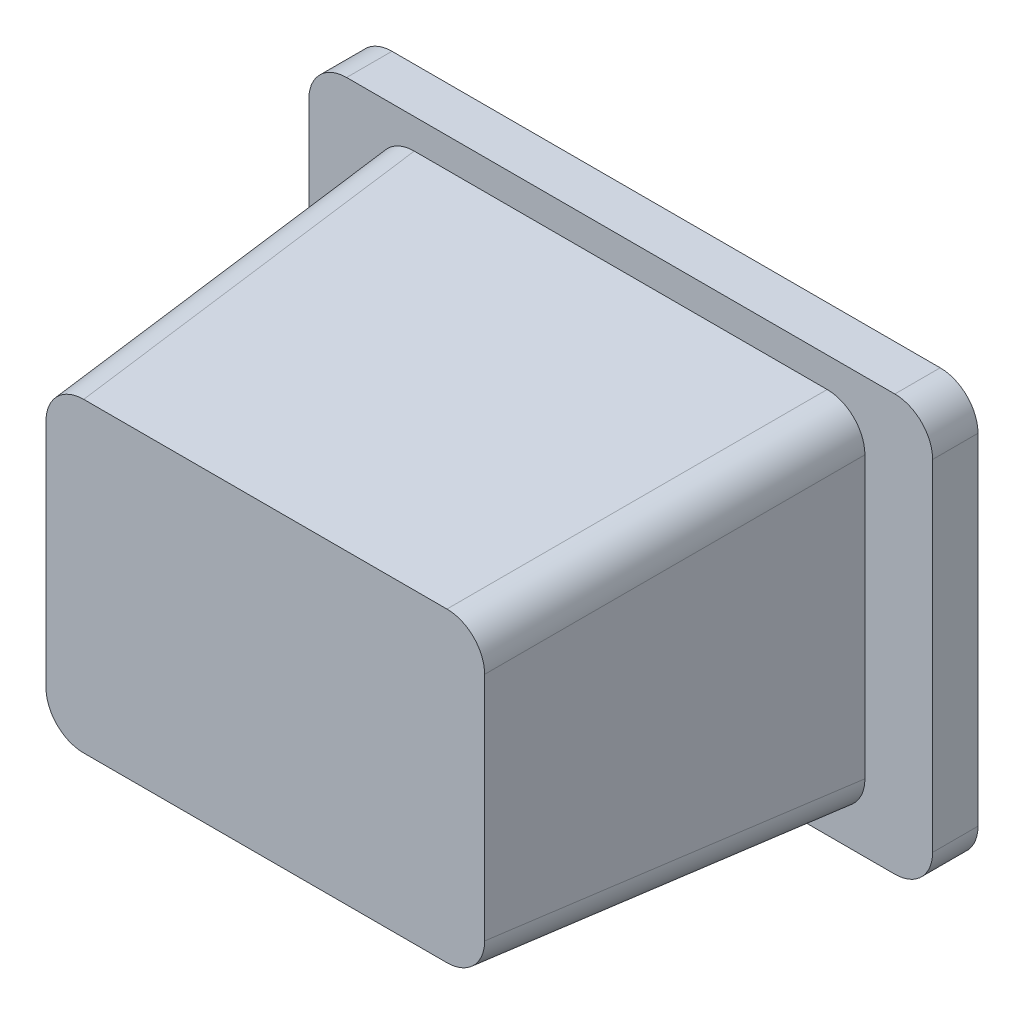
from build123d import *

# Parameters (mm, degrees)
SKETCH1_W           = 130
SKETCH1_H           = 95
BOSS_EXTRUDE1_DEPTH = 100
BOSS_EXTRUDE1_TAPER = 4
SKETCH2_W           = 165
SKETCH2_H           = 110
BOSS_EXTRUDE2_DEPTH = 6
FILLET1_R           = 10
FILLET2_R           = 10


with BuildPart() as part:
    # Sketch1 → Boss-Extrude1 (new body)
    with BuildSketch(Plane.XY):
        with Locations((-26.218487395, 19.642857143)):
            Rectangle(SKETCH1_W, SKETCH1_H)
    extrude(amount=BOSS_EXTRUDE1_DEPTH, taper=BOSS_EXTRUDE1_TAPER)

    # Sketch2 → Boss-Extrude2 (add, symmetric)
    with BuildSketch(Plane.XY):
        with Locations((-26.218487395, 19.642857143)):
            Rectangle(SKETCH2_W, SKETCH2_H)
    extrude(amount=BOSS_EXTRUDE2_DEPTH, both=True)

    # Fillet1
    fillet1_edges = [part.edges().sort_by_distance(p)[0] for p in [
        (-87.512366362, 63.43673611, 53),
        (35.075391572, 63.43673611, 53),
        (35.075391572, -24.151021824, 53),
        (-87.512366362, -24.151021824, 53),
    ]]
    fillet(fillet1_edges, radius=FILLET1_R)

    # Fillet2
    fillet2_edges = [part.edges().sort_by_distance(p)[0] for p in [
        (56.281512605, -35.357142857, 0),
        (56.281512605, 74.642857143, 0),
        (-108.718487395, 74.642857143, 0),
        (-108.718487395, -35.357142857, 0),
    ]]
    fillet(fillet2_edges, radius=FILLET2_R)


solid = part.part
